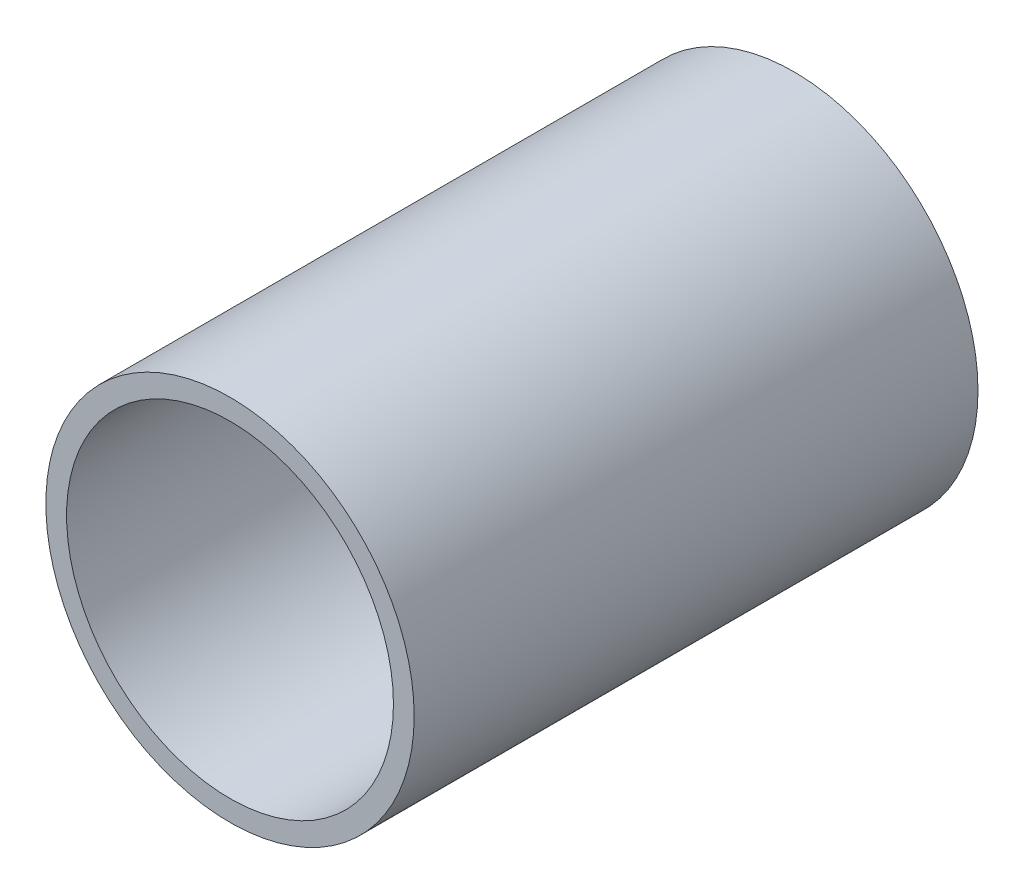
from build123d import *

# Parameters (mm, degrees)
SKETCH1_R           = 16.59255
SKETCH1_R_2         = 14.72565
BOSS_EXTRUDE1_DEPTH = 50.8


with BuildPart() as part:
    # Sketch1 → Boss-Extrude1 (new body)
    with BuildSketch(Plane.XY):
        Circle(SKETCH1_R)
        Circle(SKETCH1_R_2, mode=Mode.SUBTRACT)
    extrude(amount=BOSS_EXTRUDE1_DEPTH)


solid = part.part
